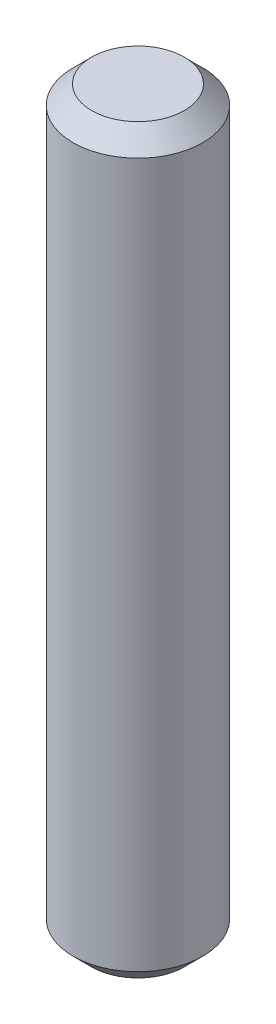
from build123d import *

# Parameters (mm, degrees)
SKETCH1_R           = 3.5
BOSS_EXTRUDE1_DEPTH = 40
CHAMFER1_SIZE       = 1


with BuildPart() as part:
    # Sketch1 → Boss-Extrude1 (new body)
    with BuildSketch(Plane(origin=(0, 0, 0), x_dir=(1, 0, 0), z_dir=(0, 1, 0))):
        Circle(SKETCH1_R)
    extrude(amount=BOSS_EXTRUDE1_DEPTH)

    # Chamfer1
    chamfer1_edges = [part.edges().sort_by_distance(p)[0] for p in [
        (-3.5, 0, 0),
        (-3.5, 40, 0),
    ]]
    chamfer(chamfer1_edges, length=CHAMFER1_SIZE)


solid = part.part
